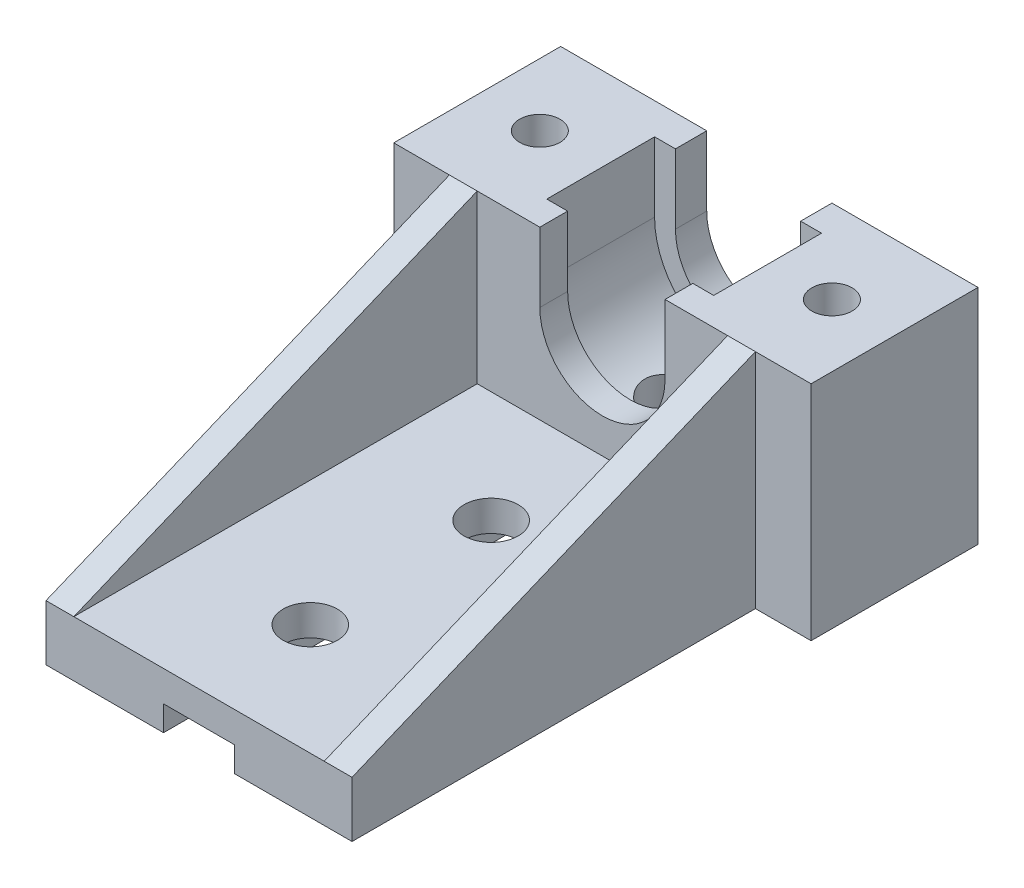
from build123d import *

# Parameters (mm, degrees)
BOSS_EXTRUDE1_DEPTH = 12
CUT_EXTRUDE1_START  = -2
CUT_EXTRUDE1_DEPTH  = 7.75
SKETCH3_R           = 1.45
CUT_EXTRUDE2_DEPTH  = 18
BOSS_EXTRUDE2_DEPTH = 29
SKETCH5_R           = 1.95
CUT_EXTRUDE3_DEPTH  = 14.5
BOSS_EXTRUDE3_DEPTH = 2
BOSS_EXTRUDE4_START = -22
BOSS_EXTRUDE4_DEPTH = 2


with BuildPart() as part:
    # Sketch1 → Boss-Extrude1 (new body)
    with BuildSketch(Plane.XY):
        with BuildLine():
            Line((-5.280588843, 25), (-5.280588843, 41))
            Line((-5.280588843, 41), (5.219411157, 41))
            Line((5.219411157, 41), (5.219411157, 36))
            ThreePointArc((5.219411157, 36), (9.719411157, 31.5), (14.219411157, 36))
            Line((14.219411157, 36), (14.219411157, 41))
            Line((14.219411157, 41), (24.719411157, 41))
            Line((24.719411157, 41), (24.719411157, 25))
            Line((24.719411157, 25), (12.269411157, 25))
            Line((12.269411157, 25), (12.269411157, 26.8))
            Line((12.269411157, 26.8), (7.169411157, 26.8))
            Line((7.169411157, 26.8), (7.169411157, 25))
            Line((7.169411157, 25), (-5.280588843, 25))
        make_face()
    extrude(amount=-BOSS_EXTRUDE1_DEPTH)

    # Sketch2 → Cut-Extrude1 (cut)
    with BuildSketch(Plane.XY.offset(CUT_EXTRUDE1_START)):
        with BuildLine():
            Line((3.719411157, 36), (3.719411157, 41))
            Line((3.719411157, 41), (15.719411157, 41))
            Line((15.719411157, 41), (15.719411157, 36))
            ThreePointArc((15.719411157, 36), (9.719411157, 30), (3.719411157, 36))
        make_face()
    extrude(amount=-CUT_EXTRUDE1_DEPTH, mode=Mode.SUBTRACT)

    # Sketch3 → Cut-Extrude2 (cut)
    with BuildSketch(Plane(origin=(0, 41, 0), x_dir=(1, 0, 0), z_dir=(0, 1, 0))):
        with Locations((20.219411157, 6)):
            Circle(SKETCH3_R)
        with Locations((-0.780588843, 6)):
            Circle(SKETCH3_R)
    extrude(amount=-CUT_EXTRUDE2_DEPTH, mode=Mode.SUBTRACT)

    # Sketch4 → Boss-Extrude2 (add)
    with BuildSketch(Plane.XY):
        Polygon((-1.280588843, 25), (-1.280588843, 29), (20.719411157, 29), (20.719411157, 25), (12.269411157, 25), (12.269411157, 26.8), (7.169411157, 26.8), (7.169411157, 25), align=None)
    extrude(amount=BOSS_EXTRUDE2_DEPTH)

    # Sketch5 → Cut-Extrude3 (cut, symmetric)
    with BuildSketch(Plane(origin=(0, 29, 0), x_dir=(1, 0, 0), z_dir=(0, 1, 0))):
        with Locations((9.719411157, -21)):
            Circle(SKETCH5_R)
        with Locations((9.719411157, -8)):
            Circle(SKETCH5_R)
        with Locations((9.719411157, 5)):
            Circle(SKETCH5_R)
    extrude(amount=CUT_EXTRUDE3_DEPTH, both=True, mode=Mode.SUBTRACT)

    # Sketch6 → Boss-Extrude3 (add)
    with BuildSketch(Plane.ZY.offset(1.280588843)):
        Polygon((29, 29), (0, 41), (0, 29), align=None)
    extrude(amount=-BOSS_EXTRUDE3_DEPTH)

    # Sketch6_2 → Boss-Extrude4 (add)
    with BuildSketch(Plane.ZY.offset(1.280588843).offset(BOSS_EXTRUDE4_START)):
        Polygon((29, 29), (0, 41), (0, 29), align=None)
    extrude(amount=BOSS_EXTRUDE4_DEPTH)


solid = part.part
